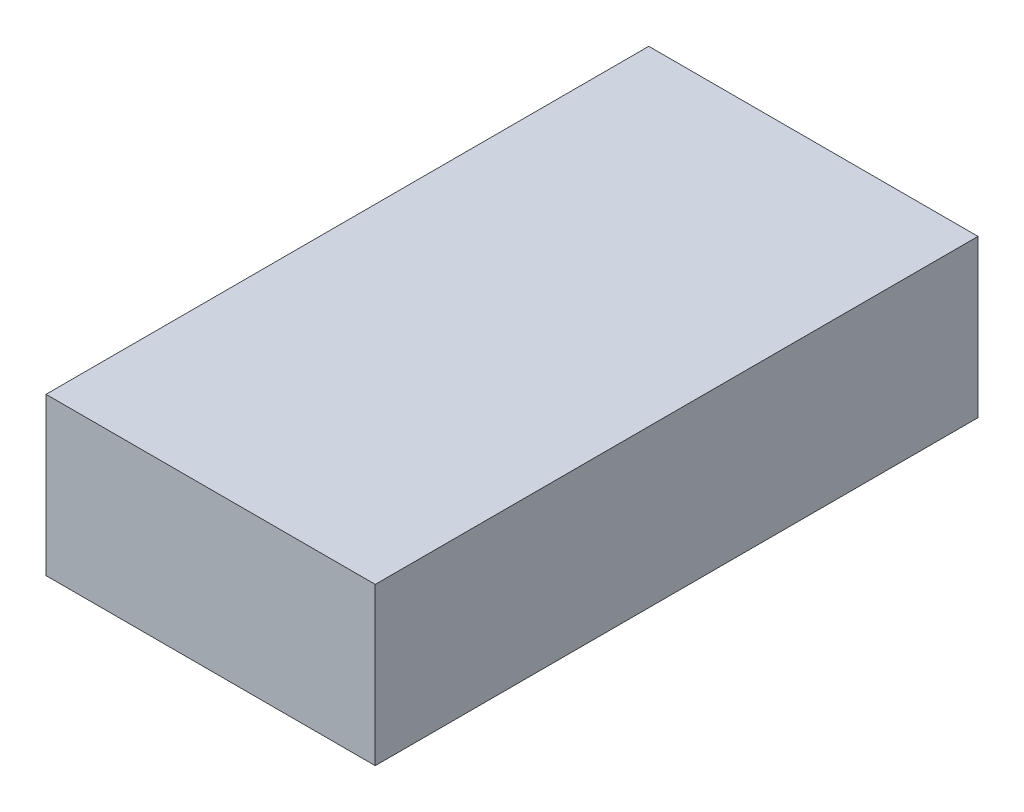
from build123d import *

# Parameters (mm, degrees)
SKETCH1_W           = 32.5
SKETCH1_H           = 59.5
BOSS_EXTRUDE1_DEPTH = 15.5


with BuildPart() as part:
    # Sketch1 → Boss-Extrude1 (new body)
    with BuildSketch(Plane(origin=(0, 0, 0), x_dir=(1, 0, 0), z_dir=(0, 1, 0))):
        Rectangle(SKETCH1_W, SKETCH1_H)
    extrude(amount=BOSS_EXTRUDE1_DEPTH)


solid = part.part
